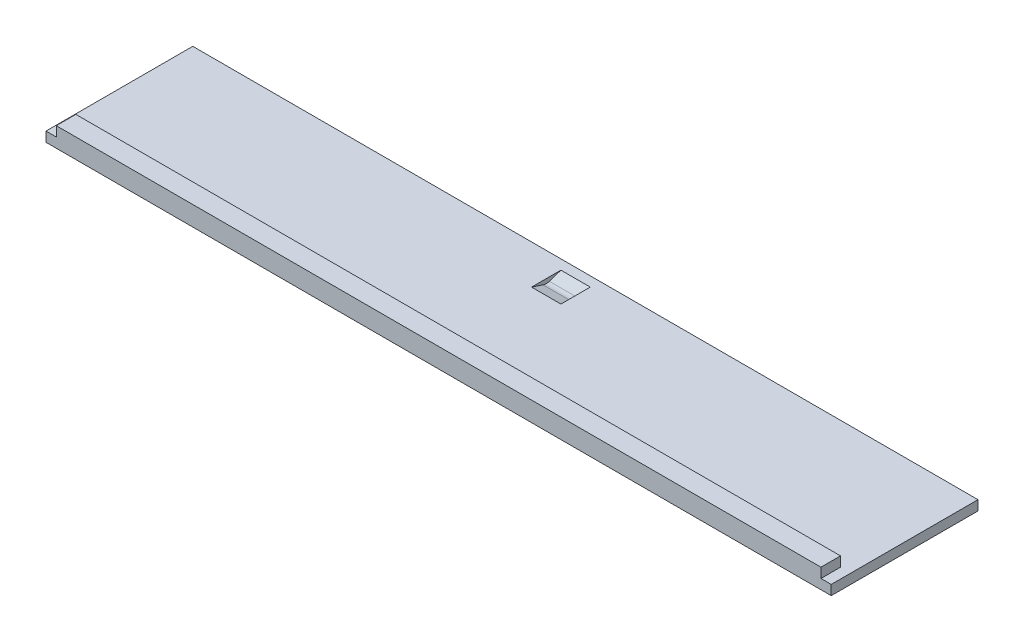
from build123d import *

# Parameters (mm, degrees)
SKETCH1_W               = 203.835
SKETCH1_H               = 38.1
BOSS_EXTRUDE1_DEPTH     = 2.54
SKETCH2_W               = 198.501
SKETCH2_H               = 2.54
BOSS_EXTRUDE2_DEPTH     = 5.08
CUT_EXTRUDE1_DEPTH      = 3.81
CUT_EXTRUDE1_DEPTH_BACK = 3.81
FILLET2_R               = 2.54


with BuildPart() as part:
    # Sketch1 → Boss-Extrude1 (new body)
    with BuildSketch(Plane(origin=(0, 0, 0), x_dir=(1, 0, 0), z_dir=(0, 1, 0))):
        Rectangle(SKETCH1_W, SKETCH1_H)
    extrude(amount=BOSS_EXTRUDE1_DEPTH)

    # Sketch2 → Boss-Extrude2 (add)
    with BuildSketch(Plane.XY.offset(19.05)):
        with Locations((0, 3.81)):
            Rectangle(SKETCH2_W, SKETCH2_H)
    extrude(amount=-BOSS_EXTRUDE2_DEPTH)

    # Sketch5 → Cut-Extrude1 (cut, two sides)
    with BuildSketch(Plane(origin=(0, 0, 0), x_dir=(0, 0, -1), z_dir=(1, 0, 0))) as cut_extrude1_sk:
        Polygon((16.51, 2.54), (12.7, 1.27), (8.89, 2.54), align=None)
    extrude(amount=CUT_EXTRUDE1_DEPTH, mode=Mode.SUBTRACT)
    extrude(cut_extrude1_sk.sketch, amount=-CUT_EXTRUDE1_DEPTH_BACK, mode=Mode.SUBTRACT)

    # Fillet2
    fillet2_edges = [part.edges().sort_by_distance(p)[0] for p in [
        (0, 1.27, -12.7),
    ]]
    fillet(fillet2_edges, radius=FILLET2_R)


solid = part.part
